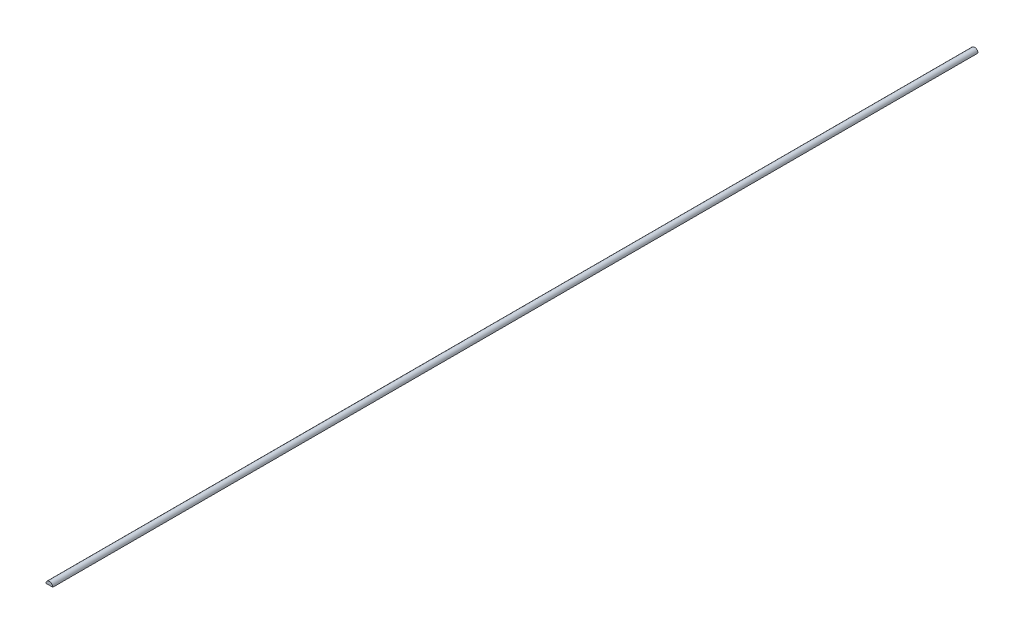
from build123d import *

# Parameters (mm, degrees)
EXTRUDE1_DEPTH = 101.95


with BuildPart() as part:
    # Sketch1 → Extrude1 (new body, symmetric)
    with BuildSketch(Plane.XY):
        with BuildLine():
            Line((-0.75, 0), (0.75, 0))
            ThreePointArc((0.75, 0), (0, 0.75), (-0.75, 0))
        make_face()
    extrude(amount=EXTRUDE1_DEPTH, both=True)


solid = part.part
